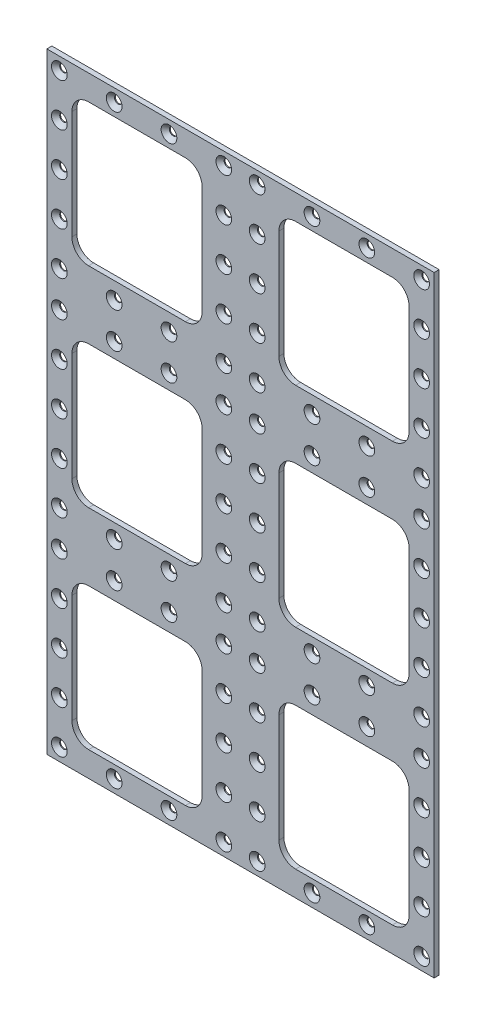
from build123d import *

# Parameters (mm, degrees)
SKETCH1_W              = 232
SKETCH1_H              = 366
BOSS_EXTRUDE1_DEPTH    = 3
SKETCH2_W              = 78
SKETCH2_H              = 85
CUT_EXTRUDE4_DEPTH     = 4
FILLET1_R              = 10
LPATTERN1_COUNT        = 3
LPATTERN1_PITCH        = 125.5
LPATTERN1_COUNT_DIR2   = 2
LPATTERN1_PITCH_DIR2   = 124
FILLET1_OF_LPATTERN1_R = 10
LPATTERN5_COUNT        = 4
LPATTERN5_PITCH        = 32.833333333
LPATTERN5_COUNT_DIR2   = 5
LPATTERN5_PITCH_DIR2   = 25.6875
LPATTERN6_COUNT        = 3
LPATTERN6_PITCH        = 124.125


with BuildPart() as part:
    # Sketch1 → Boss-Extrude1 (new body)
    with BuildSketch(Plane.XY):
        Rectangle(SKETCH1_W, SKETCH1_H)
    extrude(amount=BOSS_EXTRUDE1_DEPTH)

    # Sketch2 → Cut-Extrude4 (cut, through all)
    with BuildSketch(Plane.XY):
        with Locations((-62, 125.5)):
            Rectangle(SKETCH2_W, SKETCH2_H)
    cut_extrude4 = extrude(amount=CUT_EXTRUDE4_DEPTH, mode=Mode.SUBTRACT)

    # Fillet1
    fillet1_edges = [part.edges().sort_by_distance(p)[0] for p in [
        (-23, 83, 1.5),
        (-23, 168, 1.5),
        (-101, 168, 1.5),
        (-101, 83, 1.5),
    ]]
    fillet(fillet1_edges, radius=FILLET1_R)

    # LPattern1: Cut-Extrude4 3 × 2
    with Locations(*[(j * LPATTERN1_PITCH_DIR2, -i * LPATTERN1_PITCH, 0) for i in range(LPATTERN1_COUNT) for j in range(LPATTERN1_COUNT_DIR2) if (i, j) != (0, 0)]):
        add(cut_extrude4, mode=Mode.SUBTRACT)

    # Fillet1 of LPattern1
    fillet1_of_lpattern1_edges = [part.edges().sort_by_distance(p)[0] for p in [
        (101, 83, 1.5),
        (101, 168, 1.5),
        (23, 168, 1.5),
        (23, 83, 1.5),
        (-23, -42.5, 1.5),
        (-23, 42.5, 1.5),
        (-101, 42.5, 1.5),
        (-101, -42.5, 1.5),
        (101, -42.5, 1.5),
        (101, 42.5, 1.5),
        (23, 42.5, 1.5),
        (23, -42.5, 1.5),
        (-23, -168, 1.5),
        (-23, -83, 1.5),
        (-101, -83, 1.5),
        (-101, -168, 1.5),
        (101, -168, 1.5),
        (101, -83, 1.5),
        (23, -83, 1.5),
        (23, -168, 1.5),
    ]]
    fillet(fillet1_of_lpattern1_edges, radius=FILLET1_OF_LPATTERN1_R)

    # Sketch8 → CSK for M4 Flat Head Machine Screw3 (revolve, cut)
    with BuildSketch(Plane(origin=(-108.5, 175.5, 3), x_dir=(0, -1, 0), z_dir=(1, 0, 0))):
        Polygon((0, 0), (0, 3), (2.25, 3), (2.25, 2.45), (4.7, 0), align=None)
    csk_for_m4_flat_head_machine_screw3 = revolve(axis=Axis((-108.5, 175.5, 9.35), (0, 0, -1)), mode=Mode.SUBTRACT)

    # LPattern5: CSK for M4 Flat Head Machine Screw3 4 × 5, 6 skipped
    with Locations(*[(i * LPATTERN5_PITCH, -j * LPATTERN5_PITCH_DIR2, 0) for i in range(LPATTERN5_COUNT) for j in range(LPATTERN5_COUNT_DIR2) if (i, j) not in ((0, 0), (1, 1), (1, 2), (1, 3), (2, 1), (2, 2), (2, 3))]):
        add(csk_for_m4_flat_head_machine_screw3, mode=Mode.SUBTRACT)

    # LPattern6: CSK for M4 Flat Head Machine Screw3 ×3
    with Locations(*[(0, -i * LPATTERN6_PITCH, 0) for i in range(1, LPATTERN6_COUNT)]):
        add(csk_for_m4_flat_head_machine_screw3, mode=Mode.SUBTRACT)

    # LPattern6 copy 1 sketch → LPattern6 copy 1 (revolve, cut)
    with BuildSketch(Plane(origin=(-108.5, 25.6875, 3), x_dir=(0, -1, 0), z_dir=(1, 0, 0))):
        Polygon((0, 0), (0, 3), (2.25, 3), (2.25, 2.45), (4.7, 0), align=None)
    revolve(axis=Axis((-108.5, 25.6875, 9.35), (0, 0, -1)), mode=Mode.SUBTRACT)

    # LPattern6 copy 2 sketch → LPattern6 copy 2 (revolve, cut)
    with BuildSketch(Plane(origin=(-108.5, -98.4375, 3), x_dir=(0, -1, 0), z_dir=(1, 0, 0))):
        Polygon((0, 0), (0, 3), (2.25, 3), (2.25, 2.45), (4.7, 0), align=None)
    revolve(axis=Axis((-108.5, -98.4375, 9.35), (0, 0, -1)), mode=Mode.SUBTRACT)

    # LPattern6 copy 3 sketch → LPattern6 copy 3 (revolve, cut)
    with BuildSketch(Plane(origin=(-108.5, 0, 3), x_dir=(0, -1, 0), z_dir=(1, 0, 0))):
        Polygon((0, 0), (0, 3), (2.25, 3), (2.25, 2.45), (4.7, 0), align=None)
    revolve(axis=Axis((-108.5, 0, 9.35), (0, 0, -1)), mode=Mode.SUBTRACT)

    # LPattern6 copy 4 sketch → LPattern6 copy 4 (revolve, cut)
    with BuildSketch(Plane(origin=(-108.5, -124.125, 3), x_dir=(0, -1, 0), z_dir=(1, 0, 0))):
        Polygon((0, 0), (0, 3), (2.25, 3), (2.25, 2.45), (4.7, 0), align=None)
    revolve(axis=Axis((-108.5, -124.125, 9.35), (0, 0, -1)), mode=Mode.SUBTRACT)

    # LPattern6 copy 5 sketch → LPattern6 copy 5 (revolve, cut)
    with BuildSketch(Plane(origin=(-108.5, -25.6875, 3), x_dir=(0, -1, 0), z_dir=(1, 0, 0))):
        Polygon((0, 0), (0, 3), (2.25, 3), (2.25, 2.45), (4.7, 0), align=None)
    revolve(axis=Axis((-108.5, -25.6875, 9.35), (0, 0, -1)), mode=Mode.SUBTRACT)

    # LPattern6 copy 6 sketch → LPattern6 copy 6 (revolve, cut)
    with BuildSketch(Plane(origin=(-108.5, -149.8125, 3), x_dir=(0, -1, 0), z_dir=(1, 0, 0))):
        Polygon((0, 0), (0, 3), (2.25, 3), (2.25, 2.45), (4.7, 0), align=None)
    revolve(axis=Axis((-108.5, -149.8125, 9.35), (0, 0, -1)), mode=Mode.SUBTRACT)

    # LPattern6 copy 7 sketch → LPattern6 copy 7 (revolve, cut)
    with BuildSketch(Plane(origin=(-108.5, -51.375, 3), x_dir=(0, -1, 0), z_dir=(1, 0, 0))):
        Polygon((0, 0), (0, 3), (2.25, 3), (2.25, 2.45), (4.7, 0), align=None)
    revolve(axis=Axis((-108.5, -51.375, 9.35), (0, 0, -1)), mode=Mode.SUBTRACT)

    # LPattern6 copy 8 sketch → LPattern6 copy 8 (revolve, cut)
    with BuildSketch(Plane(origin=(-108.5, -175.5, 3), x_dir=(0, -1, 0), z_dir=(1, 0, 0))):
        Polygon((0, 0), (0, 3), (2.25, 3), (2.25, 2.45), (4.7, 0), align=None)
    revolve(axis=Axis((-108.5, -175.5, 9.35), (0, 0, -1)), mode=Mode.SUBTRACT)

    # LPattern6 copy 9 sketch → LPattern6 copy 9 (revolve, cut)
    with BuildSketch(Plane(origin=(-75.666666667, 51.375, 3), x_dir=(0, -1, 0), z_dir=(1, 0, 0))):
        Polygon((0, 0), (0, 3), (2.25, 3), (2.25, 2.45), (4.7, 0), align=None)
    revolve(axis=Axis((-75.666666667, 51.375, 9.35), (0, 0, -1)), mode=Mode.SUBTRACT)

    # LPattern6 copy 10 sketch → LPattern6 copy 10 (revolve, cut)
    with BuildSketch(Plane(origin=(-75.666666667, -72.75, 3), x_dir=(0, -1, 0), z_dir=(1, 0, 0))):
        Polygon((0, 0), (0, 3), (2.25, 3), (2.25, 2.45), (4.7, 0), align=None)
    revolve(axis=Axis((-75.666666667, -72.75, 9.35), (0, 0, -1)), mode=Mode.SUBTRACT)

    # LPattern6 copy 11 sketch → LPattern6 copy 11 (revolve, cut)
    with BuildSketch(Plane(origin=(-75.666666667, -51.375, 3), x_dir=(0, -1, 0), z_dir=(1, 0, 0))):
        Polygon((0, 0), (0, 3), (2.25, 3), (2.25, 2.45), (4.7, 0), align=None)
    revolve(axis=Axis((-75.666666667, -51.375, 9.35), (0, 0, -1)), mode=Mode.SUBTRACT)

    # LPattern6 copy 12 sketch → LPattern6 copy 12 (revolve, cut)
    with BuildSketch(Plane(origin=(-75.666666667, -175.5, 3), x_dir=(0, -1, 0), z_dir=(1, 0, 0))):
        Polygon((0, 0), (0, 3), (2.25, 3), (2.25, 2.45), (4.7, 0), align=None)
    revolve(axis=Axis((-75.666666667, -175.5, 9.35), (0, 0, -1)), mode=Mode.SUBTRACT)

    # LPattern6 copy 13 sketch → LPattern6 copy 13 (revolve, cut)
    with BuildSketch(Plane(origin=(-42.833333333, 51.375, 3), x_dir=(0, -1, 0), z_dir=(1, 0, 0))):
        Polygon((0, 0), (0, 3), (2.25, 3), (2.25, 2.45), (4.7, 0), align=None)
    revolve(axis=Axis((-42.833333333, 51.375, 9.35), (0, 0, -1)), mode=Mode.SUBTRACT)

    # LPattern6 copy 14 sketch → LPattern6 copy 14 (revolve, cut)
    with BuildSketch(Plane(origin=(-42.833333333, -72.75, 3), x_dir=(0, -1, 0), z_dir=(1, 0, 0))):
        Polygon((0, 0), (0, 3), (2.25, 3), (2.25, 2.45), (4.7, 0), align=None)
    revolve(axis=Axis((-42.833333333, -72.75, 9.35), (0, 0, -1)), mode=Mode.SUBTRACT)

    # LPattern6 copy 15 sketch → LPattern6 copy 15 (revolve, cut)
    with BuildSketch(Plane(origin=(-42.833333333, -51.375, 3), x_dir=(0, -1, 0), z_dir=(1, 0, 0))):
        Polygon((0, 0), (0, 3), (2.25, 3), (2.25, 2.45), (4.7, 0), align=None)
    revolve(axis=Axis((-42.833333333, -51.375, 9.35), (0, 0, -1)), mode=Mode.SUBTRACT)

    # LPattern6 copy 16 sketch → LPattern6 copy 16 (revolve, cut)
    with BuildSketch(Plane(origin=(-42.833333333, -175.5, 3), x_dir=(0, -1, 0), z_dir=(1, 0, 0))):
        Polygon((0, 0), (0, 3), (2.25, 3), (2.25, 2.45), (4.7, 0), align=None)
    revolve(axis=Axis((-42.833333333, -175.5, 9.35), (0, 0, -1)), mode=Mode.SUBTRACT)

    # LPattern6 copy 17 sketch → LPattern6 copy 17 (revolve, cut)
    with BuildSketch(Plane(origin=(-10, 51.375, 3), x_dir=(0, -1, 0), z_dir=(1, 0, 0))):
        Polygon((0, 0), (0, 3), (2.25, 3), (2.25, 2.45), (4.7, 0), align=None)
    revolve(axis=Axis((-10, 51.375, 9.35), (0, 0, -1)), mode=Mode.SUBTRACT)

    # LPattern6 copy 18 sketch → LPattern6 copy 18 (revolve, cut)
    with BuildSketch(Plane(origin=(-10, -72.75, 3), x_dir=(0, -1, 0), z_dir=(1, 0, 0))):
        Polygon((0, 0), (0, 3), (2.25, 3), (2.25, 2.45), (4.7, 0), align=None)
    revolve(axis=Axis((-10, -72.75, 9.35), (0, 0, -1)), mode=Mode.SUBTRACT)

    # LPattern6 copy 19 sketch → LPattern6 copy 19 (revolve, cut)
    with BuildSketch(Plane(origin=(-10, 25.6875, 3), x_dir=(0, -1, 0), z_dir=(1, 0, 0))):
        Polygon((0, 0), (0, 3), (2.25, 3), (2.25, 2.45), (4.7, 0), align=None)
    revolve(axis=Axis((-10, 25.6875, 9.35), (0, 0, -1)), mode=Mode.SUBTRACT)

    # LPattern6 copy 20 sketch → LPattern6 copy 20 (revolve, cut)
    with BuildSketch(Plane(origin=(-10, -98.4375, 3), x_dir=(0, -1, 0), z_dir=(1, 0, 0))):
        Polygon((0, 0), (0, 3), (2.25, 3), (2.25, 2.45), (4.7, 0), align=None)
    revolve(axis=Axis((-10, -98.4375, 9.35), (0, 0, -1)), mode=Mode.SUBTRACT)

    # LPattern6 copy 21 sketch → LPattern6 copy 21 (revolve, cut)
    with BuildSketch(Plane(origin=(-10, 0, 3), x_dir=(0, -1, 0), z_dir=(1, 0, 0))):
        Polygon((0, 0), (0, 3), (2.25, 3), (2.25, 2.45), (4.7, 0), align=None)
    revolve(axis=Axis((-10, 0, 9.35), (0, 0, -1)), mode=Mode.SUBTRACT)

    # LPattern6 copy 22 sketch → LPattern6 copy 22 (revolve, cut)
    with BuildSketch(Plane(origin=(-10, -124.125, 3), x_dir=(0, -1, 0), z_dir=(1, 0, 0))):
        Polygon((0, 0), (0, 3), (2.25, 3), (2.25, 2.45), (4.7, 0), align=None)
    revolve(axis=Axis((-10, -124.125, 9.35), (0, 0, -1)), mode=Mode.SUBTRACT)

    # LPattern6 copy 23 sketch → LPattern6 copy 23 (revolve, cut)
    with BuildSketch(Plane(origin=(-10, -25.6875, 3), x_dir=(0, -1, 0), z_dir=(1, 0, 0))):
        Polygon((0, 0), (0, 3), (2.25, 3), (2.25, 2.45), (4.7, 0), align=None)
    revolve(axis=Axis((-10, -25.6875, 9.35), (0, 0, -1)), mode=Mode.SUBTRACT)

    # LPattern6 copy 24 sketch → LPattern6 copy 24 (revolve, cut)
    with BuildSketch(Plane(origin=(-10, -149.8125, 3), x_dir=(0, -1, 0), z_dir=(1, 0, 0))):
        Polygon((0, 0), (0, 3), (2.25, 3), (2.25, 2.45), (4.7, 0), align=None)
    revolve(axis=Axis((-10, -149.8125, 9.35), (0, 0, -1)), mode=Mode.SUBTRACT)

    # LPattern6 copy 25 sketch → LPattern6 copy 25 (revolve, cut)
    with BuildSketch(Plane(origin=(-10, -51.375, 3), x_dir=(0, -1, 0), z_dir=(1, 0, 0))):
        Polygon((0, 0), (0, 3), (2.25, 3), (2.25, 2.45), (4.7, 0), align=None)
    revolve(axis=Axis((-10, -51.375, 9.35), (0, 0, -1)), mode=Mode.SUBTRACT)

    # LPattern6 copy 26 sketch → LPattern6 copy 26 (revolve, cut)
    with BuildSketch(Plane(origin=(-10, -175.5, 3), x_dir=(0, -1, 0), z_dir=(1, 0, 0))):
        Polygon((0, 0), (0, 3), (2.25, 3), (2.25, 2.45), (4.7, 0), align=None)
    revolve(axis=Axis((-10, -175.5, 9.35), (0, 0, -1)), mode=Mode.SUBTRACT)

    # Mirror1: CSK for M4 Flat Head Machine Screw3 across plane
    add(csk_for_m4_flat_head_machine_screw3.mirror(Plane(origin=(0, 0, 0), x_dir=(0, 0, 1), z_dir=(1, 0, 0))), mode=Mode.SUBTRACT)

    # Mirror1 copy 1 sketch → Mirror1 copy 1 (revolve, cut)
    with BuildSketch(Plane(origin=(108.5, 51.375, 3), x_dir=(0, -1, 0), z_dir=(-1, 0, 0))):
        Polygon((0, 0), (0, -3), (2.25, -3), (2.25, -2.45), (4.7, 0), align=None)
    revolve(axis=Axis((108.5, 51.375, 9.35), (0, 0, 1)), mode=Mode.SUBTRACT)

    # Mirror1 copy 2 sketch → Mirror1 copy 2 (revolve, cut)
    with BuildSketch(Plane(origin=(108.5, -72.75, 3), x_dir=(0, -1, 0), z_dir=(-1, 0, 0))):
        Polygon((0, 0), (0, -3), (2.25, -3), (2.25, -2.45), (4.7, 0), align=None)
    revolve(axis=Axis((108.5, -72.75, 9.35), (0, 0, 1)), mode=Mode.SUBTRACT)

    # Mirror1 copy 3 sketch → Mirror1 copy 3 (revolve, cut)
    with BuildSketch(Plane(origin=(108.5, 25.6875, 3), x_dir=(0, -1, 0), z_dir=(-1, 0, 0))):
        Polygon((0, 0), (0, -3), (2.25, -3), (2.25, -2.45), (4.7, 0), align=None)
    revolve(axis=Axis((108.5, 25.6875, 9.35), (0, 0, 1)), mode=Mode.SUBTRACT)

    # Mirror1 copy 4 sketch → Mirror1 copy 4 (revolve, cut)
    with BuildSketch(Plane(origin=(108.5, -98.4375, 3), x_dir=(0, -1, 0), z_dir=(-1, 0, 0))):
        Polygon((0, 0), (0, -3), (2.25, -3), (2.25, -2.45), (4.7, 0), align=None)
    revolve(axis=Axis((108.5, -98.4375, 9.35), (0, 0, 1)), mode=Mode.SUBTRACT)

    # Mirror1 copy 5 sketch → Mirror1 copy 5 (revolve, cut)
    with BuildSketch(Plane(origin=(108.5, 0, 3), x_dir=(0, -1, 0), z_dir=(-1, 0, 0))):
        Polygon((0, 0), (0, -3), (2.25, -3), (2.25, -2.45), (4.7, 0), align=None)
    revolve(axis=Axis((108.5, 0, 9.35), (0, 0, 1)), mode=Mode.SUBTRACT)

    # Mirror1 copy 6 sketch → Mirror1 copy 6 (revolve, cut)
    with BuildSketch(Plane(origin=(108.5, -124.125, 3), x_dir=(0, -1, 0), z_dir=(-1, 0, 0))):
        Polygon((0, 0), (0, -3), (2.25, -3), (2.25, -2.45), (4.7, 0), align=None)
    revolve(axis=Axis((108.5, -124.125, 9.35), (0, 0, 1)), mode=Mode.SUBTRACT)

    # Mirror1 copy 7 sketch → Mirror1 copy 7 (revolve, cut)
    with BuildSketch(Plane(origin=(108.5, -25.6875, 3), x_dir=(0, -1, 0), z_dir=(-1, 0, 0))):
        Polygon((0, 0), (0, -3), (2.25, -3), (2.25, -2.45), (4.7, 0), align=None)
    revolve(axis=Axis((108.5, -25.6875, 9.35), (0, 0, 1)), mode=Mode.SUBTRACT)

    # Mirror1 copy 8 sketch → Mirror1 copy 8 (revolve, cut)
    with BuildSketch(Plane(origin=(108.5, -149.8125, 3), x_dir=(0, -1, 0), z_dir=(-1, 0, 0))):
        Polygon((0, 0), (0, -3), (2.25, -3), (2.25, -2.45), (4.7, 0), align=None)
    revolve(axis=Axis((108.5, -149.8125, 9.35), (0, 0, 1)), mode=Mode.SUBTRACT)

    # Mirror1 copy 9 sketch → Mirror1 copy 9 (revolve, cut)
    with BuildSketch(Plane(origin=(108.5, -51.375, 3), x_dir=(0, -1, 0), z_dir=(-1, 0, 0))):
        Polygon((0, 0), (0, -3), (2.25, -3), (2.25, -2.45), (4.7, 0), align=None)
    revolve(axis=Axis((108.5, -51.375, 9.35), (0, 0, 1)), mode=Mode.SUBTRACT)

    # Mirror1 copy 10 sketch → Mirror1 copy 10 (revolve, cut)
    with BuildSketch(Plane(origin=(108.5, -175.5, 3), x_dir=(0, -1, 0), z_dir=(-1, 0, 0))):
        Polygon((0, 0), (0, -3), (2.25, -3), (2.25, -2.45), (4.7, 0), align=None)
    revolve(axis=Axis((108.5, -175.5, 9.35), (0, 0, 1)), mode=Mode.SUBTRACT)

    # Mirror1 copy 11 sketch → Mirror1 copy 11 (revolve, cut)
    with BuildSketch(Plane(origin=(75.666666667, 51.375, 3), x_dir=(0, -1, 0), z_dir=(-1, 0, 0))):
        Polygon((0, 0), (0, -3), (2.25, -3), (2.25, -2.45), (4.7, 0), align=None)
    revolve(axis=Axis((75.666666667, 51.375, 9.35), (0, 0, 1)), mode=Mode.SUBTRACT)

    # Mirror1 copy 12 sketch → Mirror1 copy 12 (revolve, cut)
    with BuildSketch(Plane(origin=(75.666666667, -72.75, 3), x_dir=(0, -1, 0), z_dir=(-1, 0, 0))):
        Polygon((0, 0), (0, -3), (2.25, -3), (2.25, -2.45), (4.7, 0), align=None)
    revolve(axis=Axis((75.666666667, -72.75, 9.35), (0, 0, 1)), mode=Mode.SUBTRACT)

    # Mirror1 copy 13 sketch → Mirror1 copy 13 (revolve, cut)
    with BuildSketch(Plane(origin=(75.666666667, -51.375, 3), x_dir=(0, -1, 0), z_dir=(-1, 0, 0))):
        Polygon((0, 0), (0, -3), (2.25, -3), (2.25, -2.45), (4.7, 0), align=None)
    revolve(axis=Axis((75.666666667, -51.375, 9.35), (0, 0, 1)), mode=Mode.SUBTRACT)

    # Mirror1 copy 14 sketch → Mirror1 copy 14 (revolve, cut)
    with BuildSketch(Plane(origin=(75.666666667, -175.5, 3), x_dir=(0, -1, 0), z_dir=(-1, 0, 0))):
        Polygon((0, 0), (0, -3), (2.25, -3), (2.25, -2.45), (4.7, 0), align=None)
    revolve(axis=Axis((75.666666667, -175.5, 9.35), (0, 0, 1)), mode=Mode.SUBTRACT)

    # Mirror1 copy 15 sketch → Mirror1 copy 15 (revolve, cut)
    with BuildSketch(Plane(origin=(42.833333333, 51.375, 3), x_dir=(0, -1, 0), z_dir=(-1, 0, 0))):
        Polygon((0, 0), (0, -3), (2.25, -3), (2.25, -2.45), (4.7, 0), align=None)
    revolve(axis=Axis((42.833333333, 51.375, 9.35), (0, 0, 1)), mode=Mode.SUBTRACT)

    # Mirror1 copy 16 sketch → Mirror1 copy 16 (revolve, cut)
    with BuildSketch(Plane(origin=(42.833333333, -72.75, 3), x_dir=(0, -1, 0), z_dir=(-1, 0, 0))):
        Polygon((0, 0), (0, -3), (2.25, -3), (2.25, -2.45), (4.7, 0), align=None)
    revolve(axis=Axis((42.833333333, -72.75, 9.35), (0, 0, 1)), mode=Mode.SUBTRACT)

    # Mirror1 copy 17 sketch → Mirror1 copy 17 (revolve, cut)
    with BuildSketch(Plane(origin=(42.833333333, -51.375, 3), x_dir=(0, -1, 0), z_dir=(-1, 0, 0))):
        Polygon((0, 0), (0, -3), (2.25, -3), (2.25, -2.45), (4.7, 0), align=None)
    revolve(axis=Axis((42.833333333, -51.375, 9.35), (0, 0, 1)), mode=Mode.SUBTRACT)

    # Mirror1 copy 18 sketch → Mirror1 copy 18 (revolve, cut)
    with BuildSketch(Plane(origin=(42.833333333, -175.5, 3), x_dir=(0, -1, 0), z_dir=(-1, 0, 0))):
        Polygon((0, 0), (0, -3), (2.25, -3), (2.25, -2.45), (4.7, 0), align=None)
    revolve(axis=Axis((42.833333333, -175.5, 9.35), (0, 0, 1)), mode=Mode.SUBTRACT)

    # Mirror1 copy 19 sketch → Mirror1 copy 19 (revolve, cut)
    with BuildSketch(Plane(origin=(10, 51.375, 3), x_dir=(0, -1, 0), z_dir=(-1, 0, 0))):
        Polygon((0, 0), (0, -3), (2.25, -3), (2.25, -2.45), (4.7, 0), align=None)
    revolve(axis=Axis((10, 51.375, 9.35), (0, 0, 1)), mode=Mode.SUBTRACT)

    # Mirror1 copy 20 sketch → Mirror1 copy 20 (revolve, cut)
    with BuildSketch(Plane(origin=(10, -72.75, 3), x_dir=(0, -1, 0), z_dir=(-1, 0, 0))):
        Polygon((0, 0), (0, -3), (2.25, -3), (2.25, -2.45), (4.7, 0), align=None)
    revolve(axis=Axis((10, -72.75, 9.35), (0, 0, 1)), mode=Mode.SUBTRACT)

    # Mirror1 copy 21 sketch → Mirror1 copy 21 (revolve, cut)
    with BuildSketch(Plane(origin=(10, 25.6875, 3), x_dir=(0, -1, 0), z_dir=(-1, 0, 0))):
        Polygon((0, 0), (0, -3), (2.25, -3), (2.25, -2.45), (4.7, 0), align=None)
    revolve(axis=Axis((10, 25.6875, 9.35), (0, 0, 1)), mode=Mode.SUBTRACT)

    # Mirror1 copy 22 sketch → Mirror1 copy 22 (revolve, cut)
    with BuildSketch(Plane(origin=(10, -98.4375, 3), x_dir=(0, -1, 0), z_dir=(-1, 0, 0))):
        Polygon((0, 0), (0, -3), (2.25, -3), (2.25, -2.45), (4.7, 0), align=None)
    revolve(axis=Axis((10, -98.4375, 9.35), (0, 0, 1)), mode=Mode.SUBTRACT)

    # Mirror1 copy 23 sketch → Mirror1 copy 23 (revolve, cut)
    with BuildSketch(Plane(origin=(10, 0, 3), x_dir=(0, -1, 0), z_dir=(-1, 0, 0))):
        Polygon((0, 0), (0, -3), (2.25, -3), (2.25, -2.45), (4.7, 0), align=None)
    revolve(axis=Axis((10, 0, 9.35), (0, 0, 1)), mode=Mode.SUBTRACT)

    # Mirror1 copy 24 sketch → Mirror1 copy 24 (revolve, cut)
    with BuildSketch(Plane(origin=(10, -124.125, 3), x_dir=(0, -1, 0), z_dir=(-1, 0, 0))):
        Polygon((0, 0), (0, -3), (2.25, -3), (2.25, -2.45), (4.7, 0), align=None)
    revolve(axis=Axis((10, -124.125, 9.35), (0, 0, 1)), mode=Mode.SUBTRACT)

    # Mirror1 copy 25 sketch → Mirror1 copy 25 (revolve, cut)
    with BuildSketch(Plane(origin=(10, -25.6875, 3), x_dir=(0, -1, 0), z_dir=(-1, 0, 0))):
        Polygon((0, 0), (0, -3), (2.25, -3), (2.25, -2.45), (4.7, 0), align=None)
    revolve(axis=Axis((10, -25.6875, 9.35), (0, 0, 1)), mode=Mode.SUBTRACT)

    # Mirror1 copy 26 sketch → Mirror1 copy 26 (revolve, cut)
    with BuildSketch(Plane(origin=(10, -149.8125, 3), x_dir=(0, -1, 0), z_dir=(-1, 0, 0))):
        Polygon((0, 0), (0, -3), (2.25, -3), (2.25, -2.45), (4.7, 0), align=None)
    revolve(axis=Axis((10, -149.8125, 9.35), (0, 0, 1)), mode=Mode.SUBTRACT)

    # Mirror1 copy 27 sketch → Mirror1 copy 27 (revolve, cut)
    with BuildSketch(Plane(origin=(10, -51.375, 3), x_dir=(0, -1, 0), z_dir=(-1, 0, 0))):
        Polygon((0, 0), (0, -3), (2.25, -3), (2.25, -2.45), (4.7, 0), align=None)
    revolve(axis=Axis((10, -51.375, 9.35), (0, 0, 1)), mode=Mode.SUBTRACT)

    # Mirror1 copy 28 sketch → Mirror1 copy 28 (revolve, cut)
    with BuildSketch(Plane(origin=(10, -175.5, 3), x_dir=(0, -1, 0), z_dir=(-1, 0, 0))):
        Polygon((0, 0), (0, -3), (2.25, -3), (2.25, -2.45), (4.7, 0), align=None)
    revolve(axis=Axis((10, -175.5, 9.35), (0, 0, 1)), mode=Mode.SUBTRACT)

    # Mirror1 copy 29 sketch → Mirror1 copy 29 (revolve, cut)
    with BuildSketch(Plane(origin=(108.5, 149.8125, 3), x_dir=(0, -1, 0), z_dir=(-1, 0, 0))):
        Polygon((0, 0), (0, -3), (2.25, -3), (2.25, -2.45), (4.7, 0), align=None)
    revolve(axis=Axis((108.5, 149.8125, 9.35), (0, 0, 1)), mode=Mode.SUBTRACT)

    # Mirror1 copy 30 sketch → Mirror1 copy 30 (revolve, cut)
    with BuildSketch(Plane(origin=(108.5, 124.125, 3), x_dir=(0, -1, 0), z_dir=(-1, 0, 0))):
        Polygon((0, 0), (0, -3), (2.25, -3), (2.25, -2.45), (4.7, 0), align=None)
    revolve(axis=Axis((108.5, 124.125, 9.35), (0, 0, 1)), mode=Mode.SUBTRACT)

    # Mirror1 copy 31 sketch → Mirror1 copy 31 (revolve, cut)
    with BuildSketch(Plane(origin=(108.5, 98.4375, 3), x_dir=(0, -1, 0), z_dir=(-1, 0, 0))):
        Polygon((0, 0), (0, -3), (2.25, -3), (2.25, -2.45), (4.7, 0), align=None)
    revolve(axis=Axis((108.5, 98.4375, 9.35), (0, 0, 1)), mode=Mode.SUBTRACT)

    # Mirror1 copy 32 sketch → Mirror1 copy 32 (revolve, cut)
    with BuildSketch(Plane(origin=(108.5, 72.75, 3), x_dir=(0, -1, 0), z_dir=(-1, 0, 0))):
        Polygon((0, 0), (0, -3), (2.25, -3), (2.25, -2.45), (4.7, 0), align=None)
    revolve(axis=Axis((108.5, 72.75, 9.35), (0, 0, 1)), mode=Mode.SUBTRACT)

    # Mirror1 copy 33 sketch → Mirror1 copy 33 (revolve, cut)
    with BuildSketch(Plane(origin=(75.666666667, 175.5, 3), x_dir=(0, -1, 0), z_dir=(-1, 0, 0))):
        Polygon((0, 0), (0, -3), (2.25, -3), (2.25, -2.45), (4.7, 0), align=None)
    revolve(axis=Axis((75.666666667, 175.5, 9.35), (0, 0, 1)), mode=Mode.SUBTRACT)

    # Mirror1 copy 34 sketch → Mirror1 copy 34 (revolve, cut)
    with BuildSketch(Plane(origin=(75.666666667, 72.75, 3), x_dir=(0, -1, 0), z_dir=(-1, 0, 0))):
        Polygon((0, 0), (0, -3), (2.25, -3), (2.25, -2.45), (4.7, 0), align=None)
    revolve(axis=Axis((75.666666667, 72.75, 9.35), (0, 0, 1)), mode=Mode.SUBTRACT)

    # Mirror1 copy 35 sketch → Mirror1 copy 35 (revolve, cut)
    with BuildSketch(Plane(origin=(42.833333333, 175.5, 3), x_dir=(0, -1, 0), z_dir=(-1, 0, 0))):
        Polygon((0, 0), (0, -3), (2.25, -3), (2.25, -2.45), (4.7, 0), align=None)
    revolve(axis=Axis((42.833333333, 175.5, 9.35), (0, 0, 1)), mode=Mode.SUBTRACT)

    # Mirror1 copy 36 sketch → Mirror1 copy 36 (revolve, cut)
    with BuildSketch(Plane(origin=(42.833333333, 72.75, 3), x_dir=(0, -1, 0), z_dir=(-1, 0, 0))):
        Polygon((0, 0), (0, -3), (2.25, -3), (2.25, -2.45), (4.7, 0), align=None)
    revolve(axis=Axis((42.833333333, 72.75, 9.35), (0, 0, 1)), mode=Mode.SUBTRACT)

    # Mirror1 copy 37 sketch → Mirror1 copy 37 (revolve, cut)
    with BuildSketch(Plane(origin=(10, 175.5, 3), x_dir=(0, -1, 0), z_dir=(-1, 0, 0))):
        Polygon((0, 0), (0, -3), (2.25, -3), (2.25, -2.45), (4.7, 0), align=None)
    revolve(axis=Axis((10, 175.5, 9.35), (0, 0, 1)), mode=Mode.SUBTRACT)

    # Mirror1 copy 38 sketch → Mirror1 copy 38 (revolve, cut)
    with BuildSketch(Plane(origin=(10, 149.8125, 3), x_dir=(0, -1, 0), z_dir=(-1, 0, 0))):
        Polygon((0, 0), (0, -3), (2.25, -3), (2.25, -2.45), (4.7, 0), align=None)
    revolve(axis=Axis((10, 149.8125, 9.35), (0, 0, 1)), mode=Mode.SUBTRACT)

    # Mirror1 copy 39 sketch → Mirror1 copy 39 (revolve, cut)
    with BuildSketch(Plane(origin=(10, 124.125, 3), x_dir=(0, -1, 0), z_dir=(-1, 0, 0))):
        Polygon((0, 0), (0, -3), (2.25, -3), (2.25, -2.45), (4.7, 0), align=None)
    revolve(axis=Axis((10, 124.125, 9.35), (0, 0, 1)), mode=Mode.SUBTRACT)

    # Mirror1 copy 40 sketch → Mirror1 copy 40 (revolve, cut)
    with BuildSketch(Plane(origin=(10, 98.4375, 3), x_dir=(0, -1, 0), z_dir=(-1, 0, 0))):
        Polygon((0, 0), (0, -3), (2.25, -3), (2.25, -2.45), (4.7, 0), align=None)
    revolve(axis=Axis((10, 98.4375, 9.35), (0, 0, 1)), mode=Mode.SUBTRACT)

    # Mirror1 copy 41 sketch → Mirror1 copy 41 (revolve, cut)
    with BuildSketch(Plane(origin=(10, 72.75, 3), x_dir=(0, -1, 0), z_dir=(-1, 0, 0))):
        Polygon((0, 0), (0, -3), (2.25, -3), (2.25, -2.45), (4.7, 0), align=None)
    revolve(axis=Axis((10, 72.75, 9.35), (0, 0, 1)), mode=Mode.SUBTRACT)


solid = part.part
